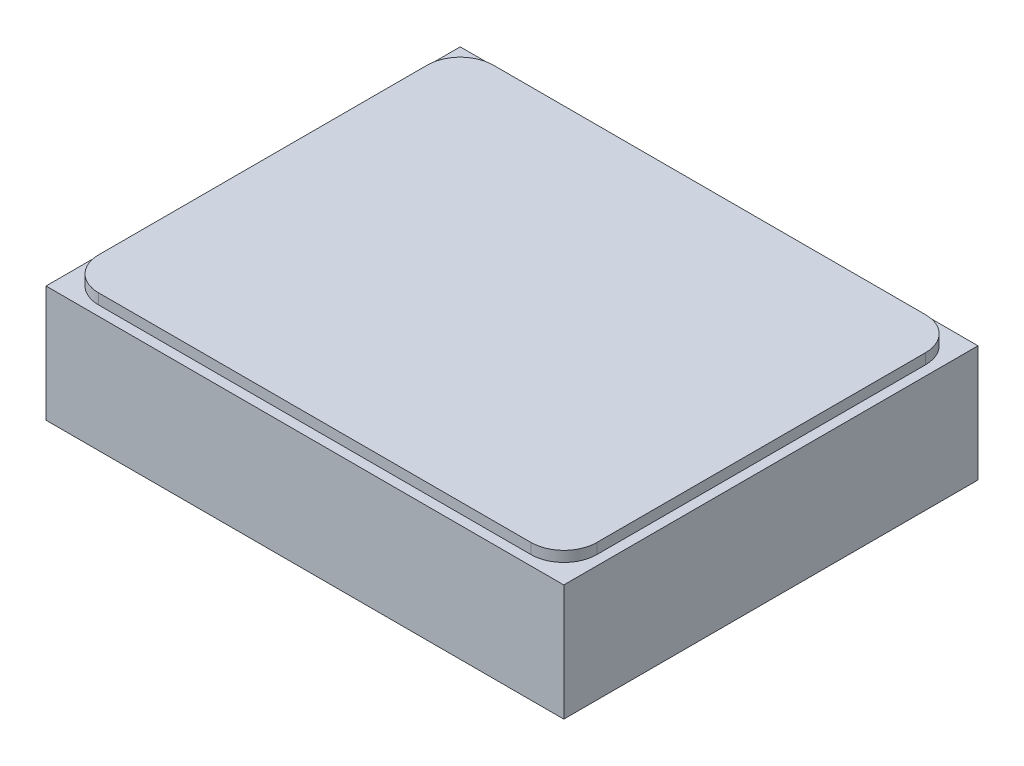
from build123d import *

# Parameters (mm, degrees)
SKETCH1_W                           = 50
SKETCH1_H                           = 40
EXTRUDE1_DEPTH                      = 11.9888
M5X0_8_TAPPED_HOLE1_D               = 4.2
M5X0_8_TAPPED_HOLE1_DEPTH           = 9.5758
M5X0_8_TAPPED_HOLE1_TIP             = 1.2618073
F_1_8_0_125_DIAMETER_HOLE1_D        = 3.175
F_1_8_0_125_DIAMETER_HOLE1_DEPTH    = 6.35
CIRPATTERN1_COUNT                   = 3
F_5_32_0_15625_DIAMETER_HOLE1_D     = 3.96875
F_5_32_0_15625_DIAMETER_HOLE1_DEPTH = 6.2484
M3X0_5_TAPPED_HOLE2_D               = 2.5
M3X0_5_TAPPED_HOLE2_DEPTH           = 5.7912
M3X0_5_TAPPED_HOLE2_TIP             = 0.751075774
CHAMFER1_SIZE                       = 0.762
EXTRUDE2_DEPTH                      = 1.016


with BuildPart() as part:
    # Sketch1 → Extrude1 (new body)
    with BuildSketch(Plane(origin=(0, 0, 0), x_dir=(1, 0, 0), z_dir=(0, 1, 0))):
        Rectangle(SKETCH1_W, SKETCH1_H)
    extrude(amount=EXTRUDE1_DEPTH)

    # M5x0.8 Tapped Hole1
    with Locations(Plane(origin=(0, 0, -20), x_dir=(-1, 0, 0), z_dir=(0, 0, -1))):
        with Locations((0, 5.334)):
            Hole(M5X0_8_TAPPED_HOLE1_D / 2, depth=M5X0_8_TAPPED_HOLE1_DEPTH)
            with Locations((0, 0, -(M5X0_8_TAPPED_HOLE1_DEPTH + M5X0_8_TAPPED_HOLE1_TIP / 2))):  # 118° drill point
                Cone(0, M5X0_8_TAPPED_HOLE1_D / 2, M5X0_8_TAPPED_HOLE1_TIP, mode=Mode.SUBTRACT)

    # 1_8 _0.125_ Diameter Hole1
    with Locations(Plane.XZ):
        with Locations((17, 0)):
            Hole(F_1_8_0_125_DIAMETER_HOLE1_D / 2, depth=F_1_8_0_125_DIAMETER_HOLE1_DEPTH)

    # Sketch8 → M3x0.5 Tapped Hole1 (revolve, cut)
    with BuildSketch(Plane(origin=(-10.795, 0, 0), x_dir=(0, 0, -1), z_dir=(1, 0, 0))):
        Polygon((0, 0), (0, 7.304275774), (1.25, 6.5532), (1.25, 0), align=None)
    m3x0_5_tapped_hole1 = revolve(axis=Axis((-10.795, -6.35, 0), (0, 1, 0)), mode=Mode.SUBTRACT)

    # CirPattern1: M3x0.5 Tapped Hole1 ×3 about axis
    cirpattern1_axis = Axis((0, 0, 0), (0, 1, 0))
    for i in range(1, CIRPATTERN1_COUNT):
        add(m3x0_5_tapped_hole1.rotate(cirpattern1_axis, i * 360 / CIRPATTERN1_COUNT), mode=Mode.SUBTRACT)

    # 5_32 _0.15625_ Diameter Hole1
    with Locations(Plane.XZ):
        with Locations((0, 0)):
            Hole(F_5_32_0_15625_DIAMETER_HOLE1_D / 2, depth=F_5_32_0_15625_DIAMETER_HOLE1_DEPTH)

    # Sketch12 → Cut-Revolve1 (revolve, cut)
    with BuildSketch(Plane.XZ.offset(0.508)):
        with BuildLine():
            Line((0, 6.5024), (0, -6.5024))
            ThreePointArc((0, -6.5024), (6.5024, 0), (0, 6.5024))
        make_face()
    revolve(axis=Axis((0, -0.508, 6.5024), (0, 0, -1)), mode=Mode.SUBTRACT)

    # M3x0.5 Tapped Hole2
    with Locations(Plane.XZ):
        with Locations((-17, 0)):
            Hole(M3X0_5_TAPPED_HOLE2_D / 2, depth=M3X0_5_TAPPED_HOLE2_DEPTH)
            with Locations((0, 0, -(M3X0_5_TAPPED_HOLE2_DEPTH + M3X0_5_TAPPED_HOLE2_TIP / 2))):  # 118° drill point
                Cone(0, M3X0_5_TAPPED_HOLE2_D / 2, M3X0_5_TAPPED_HOLE2_TIP, mode=Mode.SUBTRACT)

    # Chamfer1
    chamfer1_edges = [part.edges().sort_by_distance(p)[0] for p in [
        (0, 0, -20),
        (25, 0, 0),
        (0, 0, 20),
        (-25, 0, 0),
    ]]
    chamfer(chamfer1_edges, length=CHAMFER1_SIZE)

    # Sketch2 → Extrude2 (add)
    with BuildSketch(Plane(origin=(0, 11.9888, 0), x_dir=(-1, 0, 0), z_dir=(0, 1, 0))):
        with BuildLine():
            Line((20.8725, 19.0475), (-20.8851, 19.0475))
            ThreePointArc((-20.8851, 19.0475), (-23.13016403, 18.11756403), (-24.0601, 15.8725))
            Line((-24.0601, 15.8725), (-24.0601, -15.8775))
            ThreePointArc((-24.0601, -15.8775), (-23.13016403, -18.12256403), (-20.8851, -19.0525))
            Line((-20.8851, -19.0525), (20.8725, -19.0525))
            ThreePointArc((20.8725, -19.0525), (23.11756403, -18.12256403), (24.0475, -15.8775))
            Line((24.0475, -15.8775), (24.0475, 15.8725))
            ThreePointArc((24.0475, 15.8725), (23.11756403, 18.11756403), (20.8725, 19.0475))
        make_face()
    extrude(amount=EXTRUDE2_DEPTH)


solid = part.part
